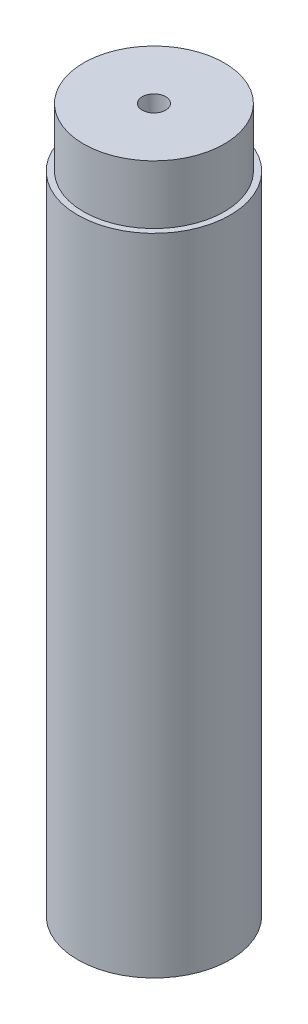
from build123d import *

# Parameters (mm, degrees)
SKETCH1_R           = 32.5
SKETCH1_R_2         = 5
BOSS_EXTRUDE1_DEPTH = 300
SKETCH2_R           = 32.5
SKETCH2_R_2         = 30
CUT_EXTRUDE2_DEPTH  = 25


with BuildPart() as part:
    # Sketch1 → Boss-Extrude1 (new body)
    with BuildSketch(Plane(origin=(0, 0, 0), x_dir=(1, 0, 0), z_dir=(0, 1, 0))):
        Circle(SKETCH1_R)
        Circle(SKETCH1_R_2, mode=Mode.SUBTRACT)
    extrude(amount=BOSS_EXTRUDE1_DEPTH)

    # Sketch2 → Cut-Extrude2 (cut)
    with BuildSketch(Plane(origin=(0, 300, 0), x_dir=(1, 0, 0), z_dir=(0, 1, 0))):
        Circle(SKETCH2_R)
        Circle(SKETCH2_R_2, mode=Mode.SUBTRACT)
    extrude(amount=-CUT_EXTRUDE2_DEPTH, mode=Mode.SUBTRACT)


solid = part.part
